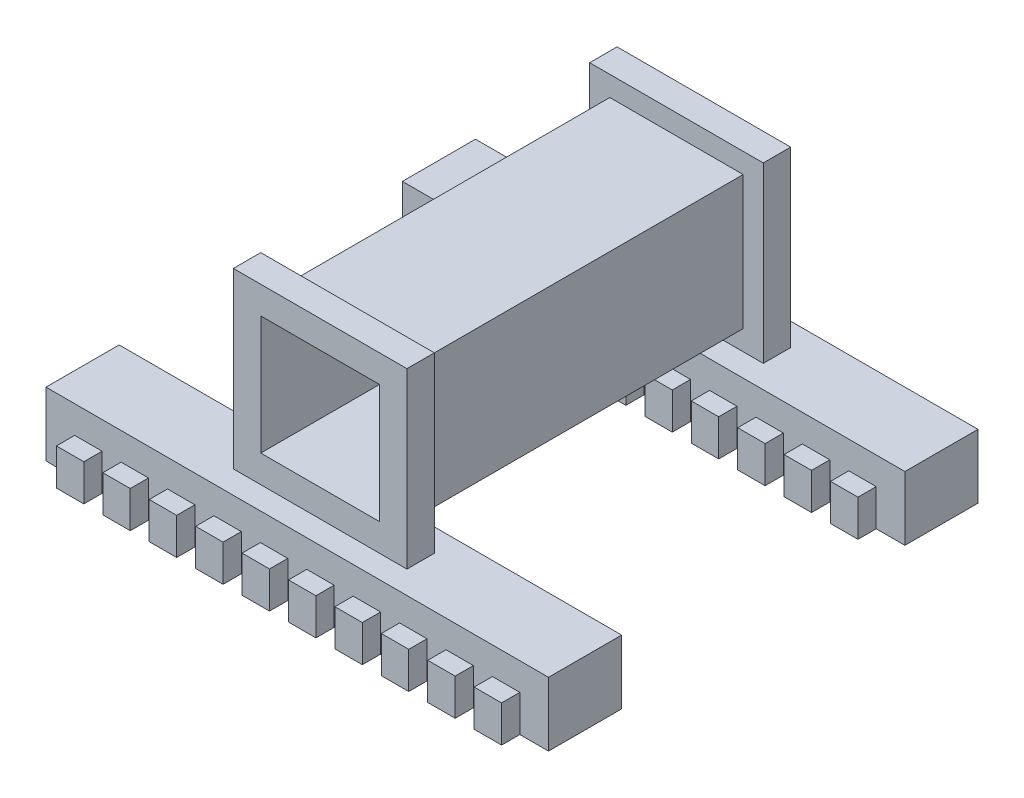
from build123d import *

# Parameters (mm, degrees)
EXTRUDE_1_DEPTH      = 21
SKETCH_1_3_W         = 13
SKETCH_1_3_H         = 13
CUT_EXTRUDE_1_DEPTH  = 21
SKETCH_1_12_W        = 19
SKETCH_1_12_H        = 19
SKETCH_1_12_W_2      = 14.6
SKETCH_1_12_H_2      = 14.6
SKETCH_1_12_W_3      = 13
SKETCH_1_12_H_3      = 13
CUT_EXTRUDE_6_DEPTH  = 18
CUT_EXTRUDE_7_DEPTH  = 14.5
SKETCH_4_W           = 3.504900739
SKETCH_4_H           = 7
SKETCH_4_W_2         = 3.5
EXTRUDE_2_DEPTH      = 27.5
SKETCH_10_W          = 1
SKETCH_10_H          = 7
EXTRUDE_4_DEPTH      = 55
SKETCH_14_W          = 1
SKETCH_14_H          = 7
EXTRUDE_6_DEPTH      = 55
CUT_EXTRUDE_22_DEPTH = 2
CUT_EXTRUDE_23_DEPTH = 2
CUT_EXTRUDE_24_DEPTH = 2
CUT_EXTRUDE_25_DEPTH = 2
SKETCH_23_W          = 49.72
SKETCH_23_H          = 6
CUT_EXTRUDE_26_DEPTH = 4


with BuildPart() as part:
    # 草图1 → 凸台-拉伸1 (new, symmetric)
    with BuildSketch(Plane.XY):
        Polygon((9.5, 9.5), (-9.5, 9.5), (-9.5, -9.5), (-27.5, -9.5), (-27.5, -16.5), (27.5, -16.5), (27.5, -9.5), (9.5, -9.5), align=None)
    extrude(amount=EXTRUDE_1_DEPTH, both=True)

    # 草图1<3> → 切除-拉伸1 (cut, symmetric)
    with BuildSketch(Plane.XY):
        Rectangle(SKETCH_1_3_W, SKETCH_1_3_H)
    extrude(amount=CUT_EXTRUDE_1_DEPTH, both=True, mode=Mode.SUBTRACT)

    # 草图1<12> → 切除-拉伸6 (cut, symmetric)
    # profile 1 of 2: a face of its own
    with BuildSketch(Plane.XY):
        Rectangle(SKETCH_1_12_W, SKETCH_1_12_H)
        Rectangle(SKETCH_1_12_W_2, SKETCH_1_12_H_2, mode=Mode.SUBTRACT)
    # profile 2 of 2: a face of its own
    with BuildSketch(Plane.XY):
        Rectangle(SKETCH_1_12_W_3, SKETCH_1_12_H_3)
    extrude(amount=CUT_EXTRUDE_6_DEPTH, both=True, mode=Mode.SUBTRACT)

    # 草图1<13> → 切除-拉伸7 (cut, symmetric)
    with BuildSketch(Plane.XY):
        Polygon((9.5, -9.5), (-9.5, -9.5), (-27.5, -9.5), (-27.5, -16.5), (27.5, -16.5), (27.5, -9.5), align=None)
    extrude(amount=CUT_EXTRUDE_7_DEPTH, both=True, mode=Mode.SUBTRACT)

    # 草图4 → 凸台-拉伸2 (add, symmetric)
    with BuildSketch(Plane(origin=(0, 0, 0), x_dir=(0, 0, -1), z_dir=(1, 0, 0))):
        with Locations((-22.752450369, -13)):
            Rectangle(SKETCH_4_W, SKETCH_4_H)
        with Locations((22.75, -13)):
            Rectangle(SKETCH_4_W_2, SKETCH_4_H)
    extrude(amount=EXTRUDE_2_DEPTH, both=True)

    # 草图10 → 凸台-拉伸4 (add)
    with BuildSketch(Plane(origin=(27.5, 0, 0), x_dir=(0, 0, -1), z_dir=(1, 0, 0))):
        with Locations((-25.004900739, -13)):
            Rectangle(SKETCH_10_W, SKETCH_10_H)
        with Locations((-14, -13)):
            Rectangle(SKETCH_10_W, SKETCH_10_H)
    extrude(amount=-EXTRUDE_4_DEPTH)

    # 草图14 → 凸台-拉伸6 (add)
    with BuildSketch(Plane(origin=(27.5, 0, 0), x_dir=(0, 0, -1), z_dir=(1, 0, 0))):
        with Locations((14, -13)):
            Rectangle(SKETCH_14_W, SKETCH_14_H)
        with Locations((25, -13)):
            Rectangle(SKETCH_14_W, SKETCH_14_H)
    extrude(amount=-EXTRUDE_6_DEPTH)

    # 草图15 → 切除-拉伸22 (cut)
    with BuildSketch(Plane(origin=(0, 0, -25.5), x_dir=(-1, 0, 0), z_dir=(0, 0, -1))):
        Polygon((-27.5, -9.5), (-27.5, -16.5), (-24.36, -16.5), (-24.36, -12.5), (-22.86, -12.5), (-21.36, -12.5), (-21.36, -16.5), (-19.28, -16.5), (-19.28, -12.5), (-17.78, -12.5), (-16.28, -12.5), (-16.28, -16.5), (-14.2, -16.5), (-14.2, -12.5), (-12.7, -12.5), (-11.2, -12.5), (-11.2, -16.5), (-9.12, -16.5), (-9.12, -12.5), (-7.62, -12.5), (-6.12, -12.5), (-6.12, -16.5), (-4.04, -16.5), (-4.04, -12.5), (-2.54, -12.5), (-1.04, -12.5), (-1.04, -16.5), (1.04, -16.5), (1.04, -12.5), (2.54, -12.5), (4.04, -12.5), (4.04, -16.5), (6.12, -16.5), (6.12, -12.5), (7.62, -12.5), (9.12, -12.5), (9.12, -16.5), (11.2, -16.5), (11.2, -12.5), (12.7, -12.5), (14.2, -12.5), (14.2, -16.5), (16.28, -16.5), (16.28, -12.5), (17.78, -12.5), (19.28, -12.5), (19.28, -16.5), (21.36, -16.5), (21.36, -12.5), (22.86, -12.5), (24.36, -12.5), (24.36, -16.5), (27.5, -16.5), (27.5, -9.5), align=None)
    extrude(amount=-CUT_EXTRUDE_22_DEPTH, mode=Mode.SUBTRACT)

    # 草图20 → 切除-拉伸23 (cut)
    with BuildSketch(Plane(origin=(0, 0, 13.5), x_dir=(-1, 0, 0), z_dir=(0, 0, -1))):
        Polygon((27.5, -9.5), (-27.5, -9.5), (-27.5, -16.5), (-24.36, -16.5), (-24.36, -12.5), (-21.36, -12.5), (-21.36, -16.5), (-19.28, -16.5), (-19.28, -12.5), (-16.28, -12.5), (-16.28, -16.5), (-14.2, -16.5), (-14.2, -12.5), (-11.2, -12.5), (-11.2, -16.5), (-9.12, -16.5), (-9.12, -12.5), (-6.12, -12.5), (-6.12, -16.5), (-4.04, -16.5), (-4.04, -12.5), (-1.04, -12.5), (-1.04, -16.5), (1.04, -16.5), (1.04, -12.5), (4.04, -12.5), (4.04, -16.5), (6.12, -16.5), (6.12, -12.5), (9.12, -12.5), (9.12, -16.5), (11.2, -16.5), (11.2, -12.5), (14.2, -12.5), (14.2, -16.5), (16.28, -16.5), (16.28, -12.5), (19.28, -12.5), (19.28, -16.5), (21.36, -16.5), (21.36, -12.5), (24.36, -12.5), (24.36, -16.5), (27.5, -16.5), align=None)
    extrude(amount=-CUT_EXTRUDE_23_DEPTH, mode=Mode.SUBTRACT)

    # 草图21 → 切除-拉伸24 (cut)
    with BuildSketch(Plane.XY.offset(-13.5)):
        Polygon((24.36, -16.5), (27.5, -16.5), (27.5, -9.5), (-27.5, -9.5), (-27.5, -16.5), (-24.36, -16.5), (-24.36, -12.5), (-21.36, -12.5), (-21.36, -16.5), (-19.28, -16.5), (-19.28, -12.5), (-16.28, -12.5), (-16.28, -16.5), (-14.2, -16.5), (-14.2, -12.5), (-11.2, -12.5), (-11.2, -16.5), (-9.12, -16.5), (-9.12, -12.5), (-6.12, -12.5), (-6.12, -16.5), (-4.04, -16.5), (-4.04, -12.5), (-1.04, -12.5), (-1.04, -16.5), (1.04, -16.5), (1.04, -12.5), (4.04, -12.5), (4.04, -16.5), (6.12, -16.5), (6.12, -12.5), (9.12, -12.5), (9.12, -16.5), (11.2, -16.5), (11.2, -12.5), (14.2, -12.5), (14.2, -16.5), (16.28, -16.5), (16.28, -12.5), (19.28, -12.5), (19.28, -16.5), (21.36, -16.5), (21.36, -12.5), (24.36, -12.5), align=None)
    extrude(amount=-CUT_EXTRUDE_24_DEPTH, mode=Mode.SUBTRACT)

    # 草图22 → 切除-拉伸25 (cut)
    with BuildSketch(Plane.XY.offset(25.504900739)):
        Polygon((24.36, -16.5), (27.5, -16.5), (27.5, -9.5), (-27.5, -9.5), (-27.5, -16.5), (-24.36, -16.5), (-24.36, -12.5), (-21.36, -12.5), (-21.36, -16.5), (-19.28, -16.5), (-19.28, -12.5), (-16.28, -12.5), (-16.28, -16.5), (-14.2, -16.5), (-14.2, -12.5), (-11.2, -12.5), (-11.2, -16.5), (-9.12, -16.5), (-9.12, -12.5), (-6.12, -12.5), (-6.12, -16.5), (-4.04, -16.5), (-4.04, -12.5), (-1.04, -12.5), (-1.04, -16.5), (1.04, -16.5), (1.04, -12.5), (4.04, -12.5), (4.04, -16.5), (6.12, -16.5), (6.12, -12.5), (9.12, -12.5), (9.12, -16.5), (11.2, -16.5), (11.2, -12.5), (14.2, -12.5), (14.2, -16.5), (16.28, -16.5), (16.28, -12.5), (19.28, -12.5), (19.28, -16.5), (21.36, -16.5), (21.36, -12.5), (24.36, -12.5), align=None)
    extrude(amount=-CUT_EXTRUDE_25_DEPTH, mode=Mode.SUBTRACT)

    # 草图23 → 切除-拉伸26 (cut)
    with BuildSketch(Plane.XZ.offset(16.5)):
        with Locations((0, 19.50245037)):
            Rectangle(SKETCH_23_W, SKETCH_23_H)
        with Locations((0, -19.50245037)):
            Rectangle(SKETCH_23_W, SKETCH_23_H)
    extrude(amount=-CUT_EXTRUDE_26_DEPTH, mode=Mode.SUBTRACT)


solid = part.part
